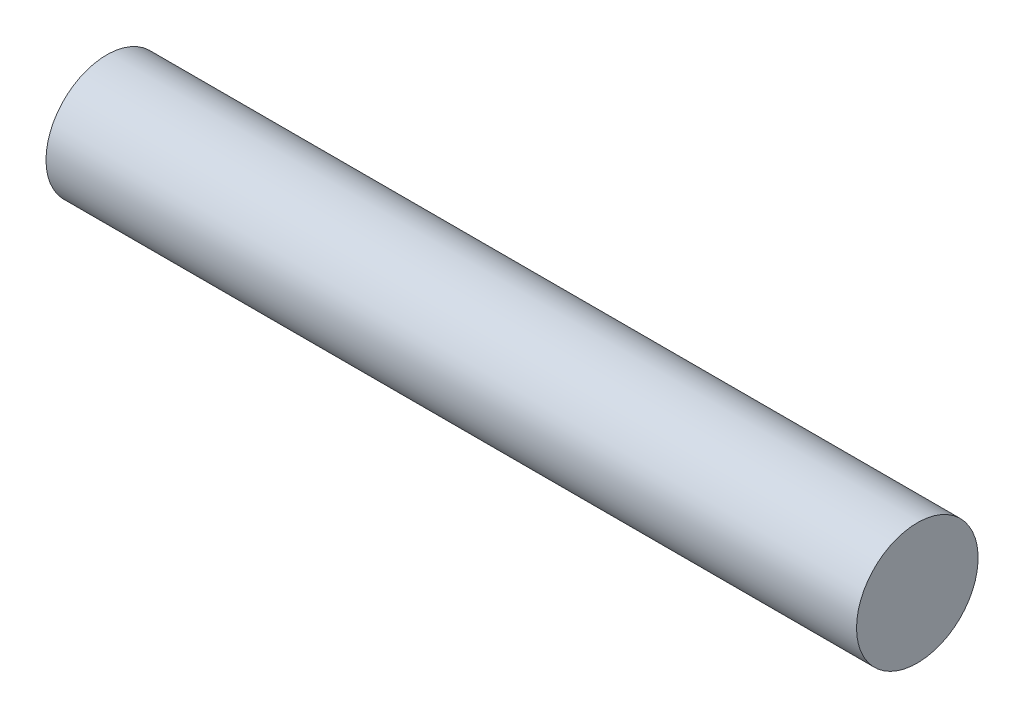
from build123d import *


with BuildPart() as part:
    # Sketch1 one side → Revolve2 (revolve)
    with BuildSketch(Plane(origin=(0, 0, 0), x_dir=(1, 0, 0), z_dir=(0, 1, 0))):
        Polygon((152.4, 0), (0, 0), (-38.1, 0), (-38.1, -17.145), (190.5, -17.145), (190.5, 0), align=None)
    revolve(axis=Axis((-38.1, 0, 17.145), (1, 0, 0)))


solid = part.part
